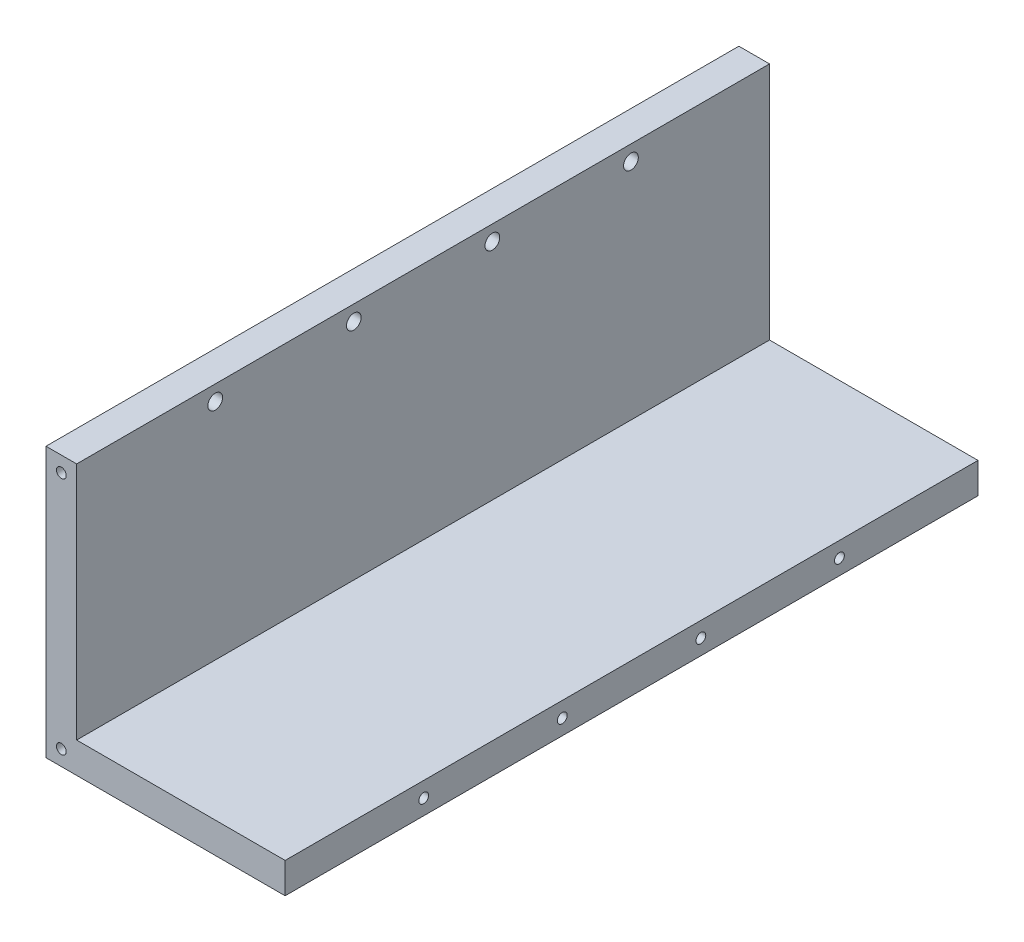
from build123d import *

# Parameters (mm, degrees)
BOSS_EXTRUDE_EQUERRE_DEPTH                     = 113
FRAISAGE_POUR_VIS_T_TE_FRAIS_E_M20_D           = 2.4
FRAISAGE_POUR_VIS_T_TE_FRAIS_E_M20_DEPTH       = 5
FRAISAGE_POUR_VIS_T_TE_FRAIS_E_M20_CSINK_D     = 4.4
FRAISAGE_POUR_VIS_T_TE_FRAIS_E_M20_CSINK_ANGLE = 90
FRAISAGE_POUR_VIS_T_TE_FRAIS_E_M20_TIP         = 0.721032743
TROU_TARAUD_M2X0_43_D                          = 1.6
TROU_TARAUD_M2X0_43_DEPTH                      = 8
TROU_TARAUD_M2X0_43_TIP                        = 0.480688495
TROU_TARAUD_M2X0_44_AT_2_COUNT                 = 2
TROU_TARAUD_M2X0_44_AT_2_PITCH                 = 39


with BuildPart() as part:
    # Esquisse1 → Boss_Extrude_Equerre (new body)
    with BuildSketch(Plane(origin=(0, 0, 0), x_dir=(0, 1, 0), z_dir=(0, 0, 1))):
        Polygon((0, 0), (39, 0), (39, 5), (-5, 5), (-5, 0), (-5, -34), (0, -34), align=None)
    extrude(amount=BOSS_EXTRUDE_EQUERRE_DEPTH)

    # Fraisage pour vis à tête fraisée M20
    with Locations(Plane.ZY.offset(5)):
        with Locations((67.8, 36.5), (90.4, 36.5), (45.2, 36.5), (22.6, 36.5)):
            CounterSinkHole(FRAISAGE_POUR_VIS_T_TE_FRAIS_E_M20_D / 2, FRAISAGE_POUR_VIS_T_TE_FRAIS_E_M20_CSINK_D / 2, depth=FRAISAGE_POUR_VIS_T_TE_FRAIS_E_M20_DEPTH, counter_sink_angle=FRAISAGE_POUR_VIS_T_TE_FRAIS_E_M20_CSINK_ANGLE)
            with Locations((0, 0, -(FRAISAGE_POUR_VIS_T_TE_FRAIS_E_M20_DEPTH + FRAISAGE_POUR_VIS_T_TE_FRAIS_E_M20_TIP / 2))):  # 118° drill point
                Cone(0, FRAISAGE_POUR_VIS_T_TE_FRAIS_E_M20_D / 2, FRAISAGE_POUR_VIS_T_TE_FRAIS_E_M20_TIP, mode=Mode.SUBTRACT)

    # Trou taraudé M2x0.43
    with Locations(Plane.YZ.offset(34)):
        with Locations((-2.5, 67.8), (-2.5, 90.4), (-2.5, 45.2), (-2.5, 22.6)):
            Hole(TROU_TARAUD_M2X0_43_D / 2, depth=TROU_TARAUD_M2X0_43_DEPTH)
            with Locations((0, 0, -(TROU_TARAUD_M2X0_43_DEPTH + TROU_TARAUD_M2X0_43_TIP / 2))):  # 118° drill point
                Cone(0, TROU_TARAUD_M2X0_43_D / 2, TROU_TARAUD_M2X0_43_TIP, mode=Mode.SUBTRACT)

    # Esquisse11 → Trou taraudé M2x0.44 (revolve, cut)
    with BuildSketch(Plane(origin=(-2.5, 36.5, 113), x_dir=(0, -1, 0), z_dir=(1, 0, 0))):
        Polygon((0, 0), (0, 8.480688495), (0.8, 8), (0.8, 0), align=None)
    trou_taraud_m2x0_44 = revolve(axis=Axis((-2.5, 36.5, 119.35), (0, 0, -1)), mode=Mode.SUBTRACT)

    # Trou taraudé M2x0.44 at 2: Trou taraudé M2x0.44 ×2
    with Locations(*[(0, -i * TROU_TARAUD_M2X0_44_AT_2_PITCH, 0) for i in range(1, TROU_TARAUD_M2X0_44_AT_2_COUNT)]):
        add(trou_taraud_m2x0_44, mode=Mode.SUBTRACT)

    # Symétrie1: Trou taraudé M2x0.44 across plane
    add(trou_taraud_m2x0_44.mirror(Plane.XY.offset(56.5)), mode=Mode.SUBTRACT)

    # Symétrie1 copy 1 sketch → Symétrie1 copy 1 (revolve, cut)
    with BuildSketch(Plane(origin=(-2.5, -2.5, 0), x_dir=(0, -1, 0), z_dir=(1, 0, 0))):
        Polygon((0, 0), (0, -8.480688495), (0.8, -8), (0.8, 0), align=None)
    revolve(axis=Axis((-2.5, -2.5, -6.35), (0, 0, -1)), mode=Mode.SUBTRACT)


solid = part.part
